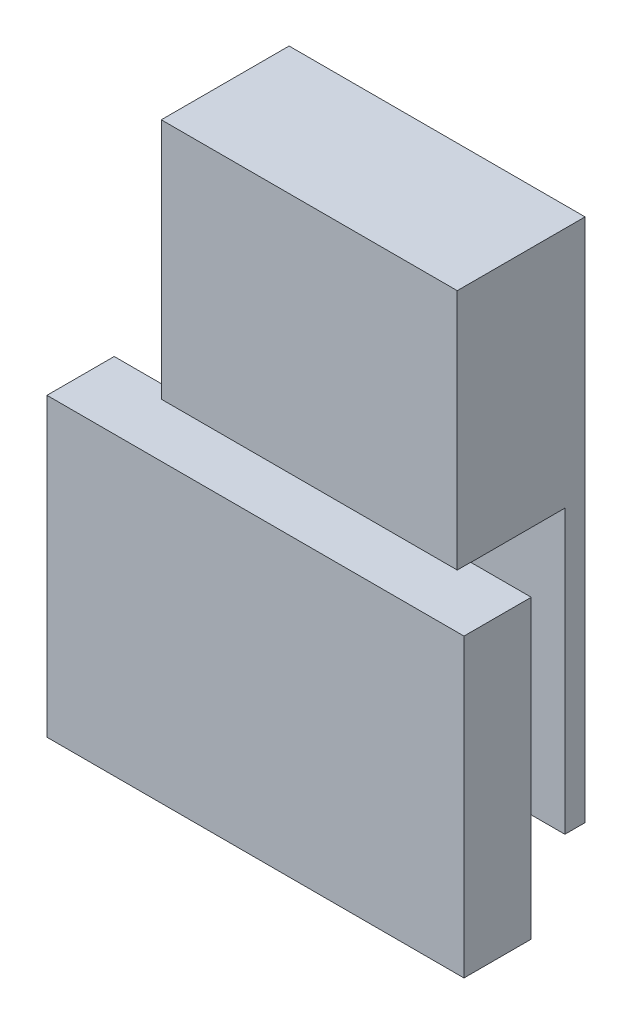
from build123d import *

# Parameters (mm, degrees)
SKETCH1_W                = 55.88
SKETCH1_H                = 99.06
BOSS_EXTRUDE1_DEPTH      = 3.81
SKETCH2_W                = 55.88
SKETCH2_H                = 45.72
BOSS_EXTRUDE2_DEPTH      = 20.32
SKETCH3_W                = 55.88
SKETCH3_H                = 2.54
BOSS_EXTRUDE3_DEPTH      = 55.88
SKETCH4_W                = 11.43
SKETCH4_H                = 55.911789182
SKETCH4_W_2              = 55.88
BOSS_EXTRUDE4_DEPTH      = 10.16
BOSS_EXTRUDE4_DEPTH_BACK = 2.54


with BuildPart() as part:
    # Sketch1 → Boss-Extrude1 (new body)
    with BuildSketch(Plane.XY):
        Rectangle(SKETCH1_W, SKETCH1_H)
    extrude(amount=BOSS_EXTRUDE1_DEPTH)

    # Sketch2 → Boss-Extrude2 (add)
    with BuildSketch(Plane.XY.offset(3.81)):
        with Locations((0, 26.67)):
            Rectangle(SKETCH2_W, SKETCH2_H)
    extrude(amount=BOSS_EXTRUDE2_DEPTH)

    # Sketch3 → Boss-Extrude3 (add)
    with BuildSketch(Plane.XZ.offset(-3.81)):
        with Locations((0, 22.86)):
            Rectangle(SKETCH3_W, SKETCH3_H)
    extrude(amount=BOSS_EXTRUDE3_DEPTH)

    # Sketch4 → Boss-Extrude4 (add, two sides)
    with BuildSketch(Plane.XY.offset(24.13)) as boss_extrude4_sk:
        with Locations((-33.655, -24.114105409)):
            Rectangle(SKETCH4_W, SKETCH4_H)
        with Locations((0, -24.114105409)):
            Rectangle(SKETCH4_W_2, SKETCH4_H)
        with Locations((33.655, -24.114105409)):
            Rectangle(SKETCH4_W, SKETCH4_H)
    extrude(amount=BOSS_EXTRUDE4_DEPTH)
    extrude(boss_extrude4_sk.sketch, amount=-BOSS_EXTRUDE4_DEPTH_BACK)


solid = part.part
